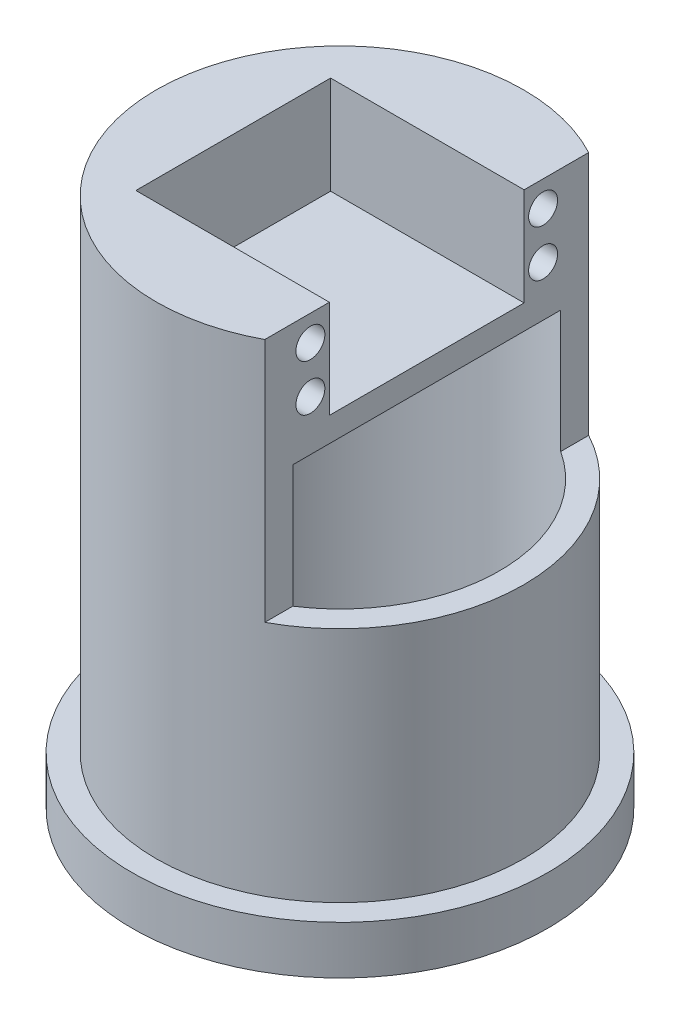
from build123d import *

# Parameters (mm, degrees)
SKETCH1_R           = 38.1
BOSS_EXTRUDE1_DEPTH = 100
SHELL1_T            = -5
SKETCH2_R           = 43.1
SKETCH2_R_2         = 33.1
BOSS_EXTRUDE2_DEPTH = 10
BOSS_EXTRUDE3_DEPTH = 5
CUT_EXTRUDE1_DEPTH  = 5
BOSS_EXTRUDE4_DEPTH = 25.4
CUT_EXTRUDE3_DEPTH  = 50.8
SKETCH9_R           = 3
SKETCH9_W           = 40.386
SKETCH9_H           = 20.32
CUT_EXTRUDE4_DEPTH  = 40.132


with BuildPart() as part:
    # Sketch1 → Boss-Extrude1 (new body)
    with BuildSketch(Plane(origin=(0, 0, 0), x_dir=(1, 0, 0), z_dir=(0, 1, 0))):
        with Locations(Location((0, 0, 0), (0, 0, 270))):
            Circle(SKETCH1_R)
    extrude(amount=BOSS_EXTRUDE1_DEPTH)

    # Shell1
    shell1_openings = [part.faces().sort_by_distance(p)[0] for p in [
        (0, 100, 0),
        (0, 0, 0),
    ]]
    offset(amount=SHELL1_T, openings=shell1_openings, kind=Kind.INTERSECTION)

    # Sketch2 → Boss-Extrude2 (add)
    with BuildSketch(Plane.XZ):
        with Locations(Location((0, 0, 0), (0, 0, 270))):
            Circle(SKETCH2_R)
        with Locations(Location((0, 0, 0), (0, 0, 270))):
            Circle(SKETCH2_R_2, mode=Mode.SUBTRACT)
    extrude(amount=BOSS_EXTRUDE2_DEPTH)

    # Sketch4 → Boss-Extrude3 (add)
    with BuildSketch(Plane.XZ.offset(10)):
        with BuildLine():
            ThreePointArc((-13, 30.440269381), (-5.381039934, 0), (-13, -30.440269381))
            ThreePointArc((-13, -30.440269381), (0, -33.1), (13, -30.440269381))
            ThreePointArc((13, -30.440269381), (5.381039934, 0), (13, 30.440269381))
            ThreePointArc((13, 30.440269381), (0, 33.1), (-13, 30.440269381))
        make_face()
    extrude(amount=-BOSS_EXTRUDE3_DEPTH)

    # Sketch5 → Cut-Extrude1 (cut)
    with BuildSketch(Plane.XZ.offset(10)):
        with BuildLine():
            Line((-2, 1.5), (2, 1.5))
            ThreePointArc((2, 1.5), (2.5, 0), (2, -1.5))
            Line((2, -1.5), (-2, -1.5))
            ThreePointArc((-2, -1.5), (-2.5, 0), (-2, 1.5))
        make_face()
    extrude(amount=-CUT_EXTRUDE1_DEPTH, mode=Mode.SUBTRACT)

    # Sketch6 → Boss-Extrude4 (add)
    with BuildSketch(Plane(origin=(0, 100, 0), x_dir=(1, 0, 0), z_dir=(0, 1, 0))):
        with BuildLine():
            Line((18, 33.579904705), (18, -33.579904705))
            ThreePointArc((18, -33.579904705), (-38.1, 0), (18, 33.579904705))
        make_face()
    extrude(amount=-BOSS_EXTRUDE4_DEPTH)

    # Sketch8 → Cut-Extrude3 (cut)
    with BuildSketch(Plane(origin=(0, 100, 0), x_dir=(1, 0, 0), z_dir=(0, 1, 0))):
        with BuildLine():
            Line((18, -42.955320998), (18, 42.955320998))
            ThreePointArc((18, 42.955320998), (52.271949939, 0), (18, -42.955320998))
        make_face()
    extrude(amount=-CUT_EXTRUDE3_DEPTH, mode=Mode.SUBTRACT)

    # Sketch9 → Cut-Extrude4 (cut)
    with BuildSketch(Plane(origin=(18, 0, 0), x_dir=(0, 0, -1), z_dir=(1, 0, 0))):
        with Locations((-24.13, 94.666)):
            Circle(SKETCH9_R)
        with Locations((-24.13, 85.014)):
            Circle(SKETCH9_R)
        with Locations(Location((24.13, 85.014, 0), (0, 0, 180))):
            Circle(SKETCH9_R)
        with Locations(Location((24.13, 94.666, 0), (0, 0, 180))):
            Circle(SKETCH9_R)
        with Locations((0, 89.84)):
            Rectangle(SKETCH9_W, SKETCH9_H)
    extrude(amount=-CUT_EXTRUDE4_DEPTH, mode=Mode.SUBTRACT)


solid = part.part
